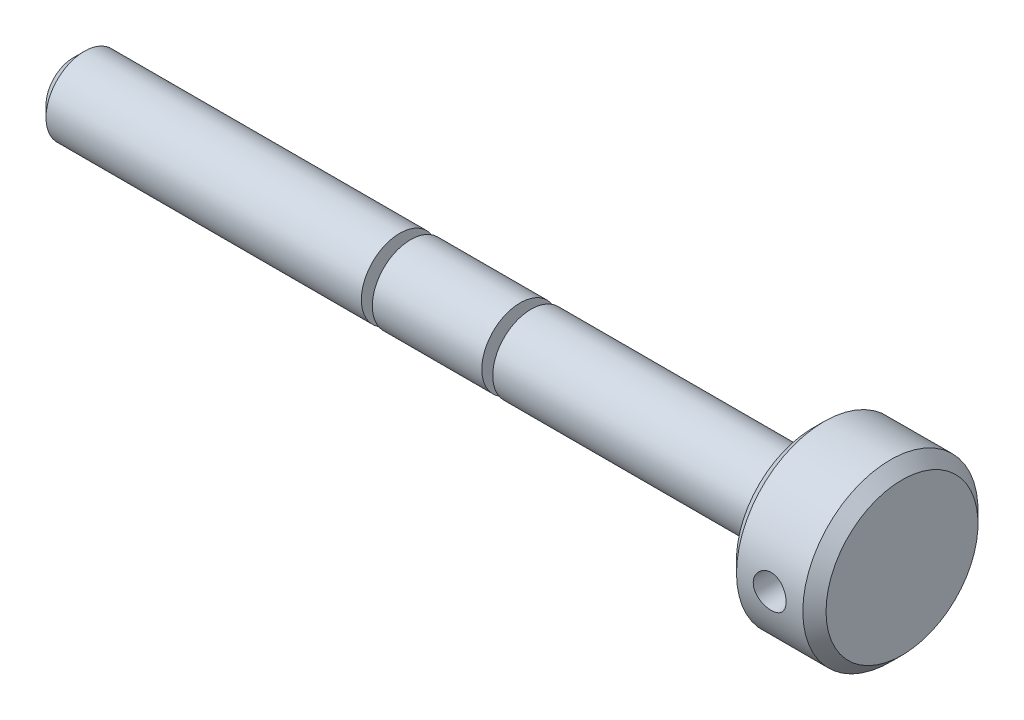
from build123d import *

# Parameters (mm, degrees)
CHAMFER1_SIZE           = 2
CHAMFER2_SIZE           = 2.1213
CUT_EXTRUDE1_DEPTH      = 135
CUT_EXTRUDE1_DEPTH_BACK = 135
SKETCH3_R               = 3


with BuildPart() as part:
    # Sketch2 → Revolve1 (revolve)
    with BuildSketch(Plane.XY):
        Polygon((-76.638954869, 0), (74.714964371, 0), (74.714964371, 16), (58.361045131, 16), (58.361045131, 7), (6.961045131, 7), (6.961045131, 2.991686461), (4.961045131, 2.991686461), (4.961045131, 7), (-15.038954869, 7), (-15.038954869, 2.991686461), (-17.038954869, 2.991686461), (-17.038954869, 7), (-76.638954869, 7), align=None)
    revolve(axis=Axis((-76.638954869, 0, 0), (1, 0, 0)))

    # Chamfer1
    chamfer1_edges = [part.edges().sort_by_distance(p)[0] for p in [
        (-76.638954869, -7, 0),
    ]]
    chamfer(chamfer1_edges, length=CHAMFER1_SIZE)

    # Chamfer2
    chamfer2_edges = [part.edges().sort_by_distance(p)[0] for p in [
        (58.361045131, -16, 0),
        (74.714964371, -16, 0),
    ]]
    chamfer(chamfer2_edges, length=CHAMFER2_SIZE)

    # Sketch3 → Cut-Extrude1 (cut, two sides: drawn at the far end of the back side and taken through both)
    with BuildSketch(Plane.XY.offset(-CUT_EXTRUDE1_DEPTH_BACK)):
        with Locations((66.538004751, 0)):
            Circle(SKETCH3_R)
    extrude(amount=CUT_EXTRUDE1_DEPTH + CUT_EXTRUDE1_DEPTH_BACK, mode=Mode.SUBTRACT)


solid = part.part
